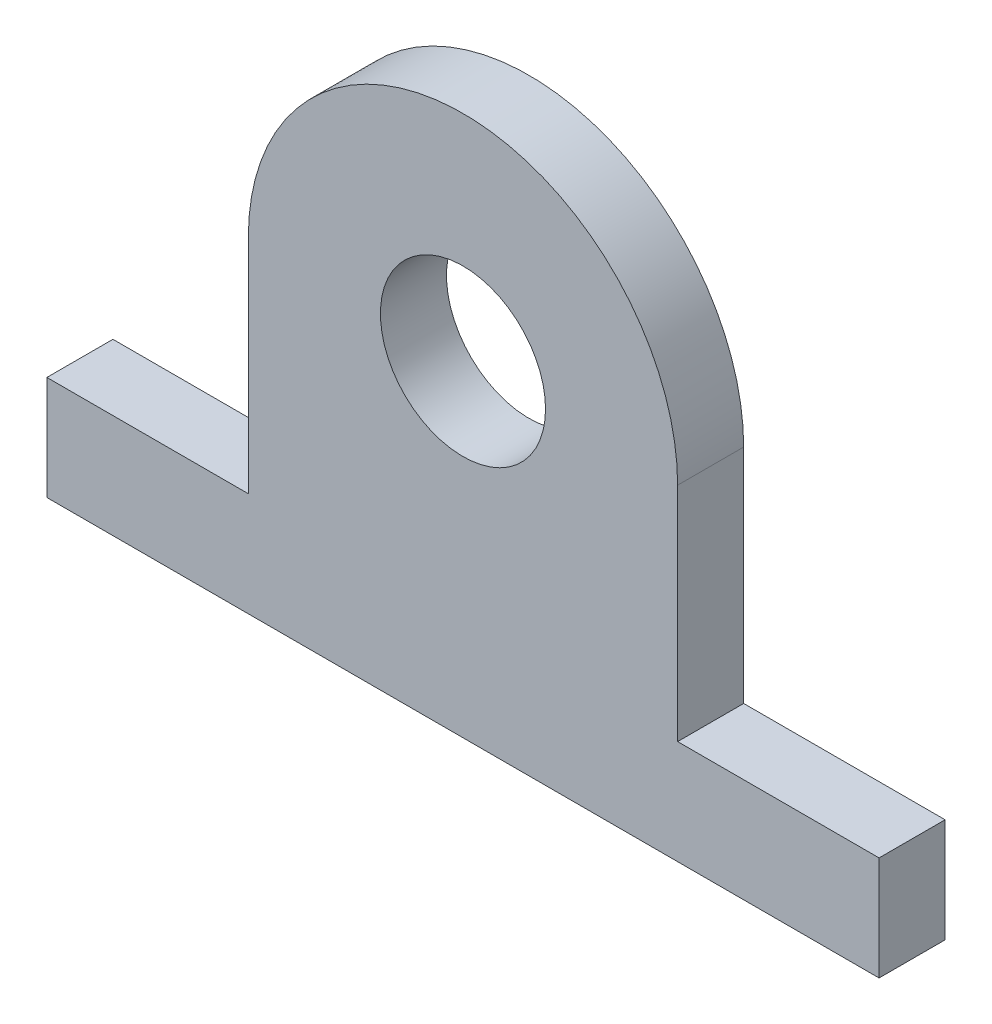
from build123d import *

# Parameters (mm, degrees)
SKETCH1_R           = 7.9375
BOSS_EXTRUDE1_DEPTH = 6.35


with BuildPart() as part:
    # Sketch1 → Boss-Extrude1 (new body)
    with BuildSketch(Plane.XY):
        with BuildLine():
            Line((-40.005, -31.35), (40.005, -31.35))
            Line((40.005, -31.35), (40.005, -21.35))
            Line((40.005, -21.35), (20.6375, -21.35))
            Line((20.6375, -21.35), (20.6375, 0))
            ThreePointArc((20.6375, 0), (0, 20.6375), (-20.6375, 0))
            Line((-20.6375, 0), (-20.6375, -21.35))
            Line((-20.6375, -21.35), (-40.005, -21.35))
            Line((-40.005, -21.35), (-40.005, -31.35))
        make_face()
        Circle(SKETCH1_R, mode=Mode.SUBTRACT)
    extrude(amount=BOSS_EXTRUDE1_DEPTH)


solid = part.part
